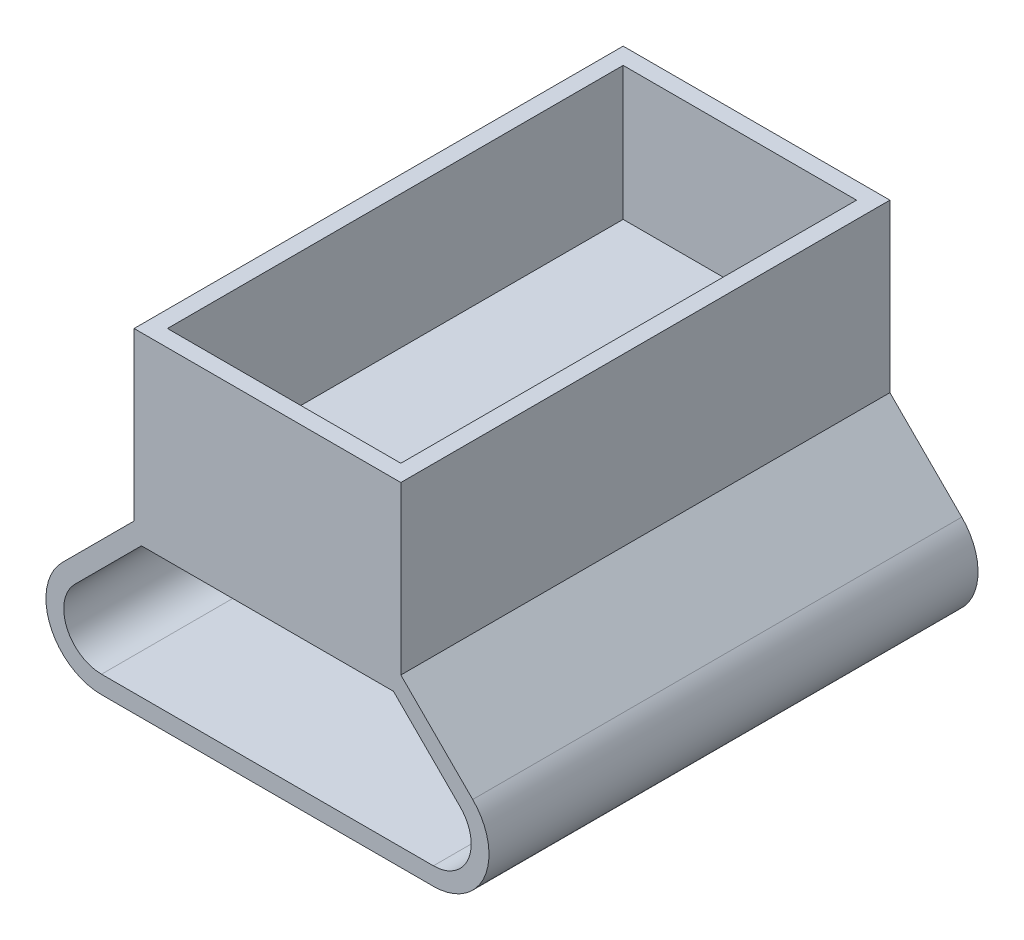
from build123d import *

# Parameters (mm, degrees)
BOSS_EXTRUDE1_DEPTH = 44
CUT_EXTRUDE1_DEPTH  = 51.578279312
SKETCH2_W           = 24
SKETCH2_H           = 44
SKETCH2_W_2         = 21
SKETCH2_H_2         = 41
BOSS_EXTRUDE2_DEPTH = 15
SKETCH2_2_W         = 21
SKETCH2_2_H         = 41
BOSS_EXTRUDE3_DEPTH = 3


with BuildPart() as part:
    # Sketch1 → Boss-Extrude1 (new body)
    with BuildSketch(Plane.XY):
        with BuildLine():
            Line((-12, 0), (12, 0))
            Line((12, 0), (18.464466094, -6.464466094))
            ThreePointArc((18.464466094, -6.464466094), (19.548329851, -11.913417162), (14.928932188, -15))
            Line((14.928932188, -15), (-14.928932188, -15))
            ThreePointArc((-14.928932188, -15), (-19.548329851, -11.913417162), (-18.464466094, -6.464466094))
            Line((-18.464466094, -6.464466094), (-12, 0))
        make_face()
    extrude(amount=BOSS_EXTRUDE1_DEPTH)

    # Sketch3 → Cut-Extrude1 (cut, through all)
    with BuildSketch(Plane.XY.offset(44)):
        with BuildLine():
            Line((-14.928932188, -13.4), (14.928932188, -13.4))
            ThreePointArc((14.928932188, -13.4), (18.070122599, -11.30112367), (17.333095244, -7.595836944))
            Line((17.333095244, -7.595836944), (11.3372583, -1.6))
            Line((11.3372583, -1.6), (-11.3372583, -1.6))
            Line((-11.3372583, -1.6), (-17.333095244, -7.595836944))
            ThreePointArc((-17.333095244, -7.595836944), (-18.070122599, -11.30112367), (-14.928932188, -13.4))
        make_face()
    extrude(amount=-CUT_EXTRUDE1_DEPTH, mode=Mode.SUBTRACT)

    # Sketch2 → Boss-Extrude2 (add)
    with BuildSketch(Plane(origin=(0, 0, 0), x_dir=(1, 0, 0), z_dir=(0, 1, 0))):
        with Locations((0, -22)):
            Rectangle(SKETCH2_W, SKETCH2_H)
        with Locations((0, -22)):
            Rectangle(SKETCH2_W_2, SKETCH2_H_2, mode=Mode.SUBTRACT)
    extrude(amount=BOSS_EXTRUDE2_DEPTH)

    # Sketch2_2 → Boss-Extrude3 (add)
    with BuildSketch(Plane(origin=(0, 0, 0), x_dir=(1, 0, 0), z_dir=(0, 1, 0))):
        with Locations((0, -22)):
            Rectangle(SKETCH2_2_W, SKETCH2_2_H)
    extrude(amount=BOSS_EXTRUDE3_DEPTH)


solid = part.part
